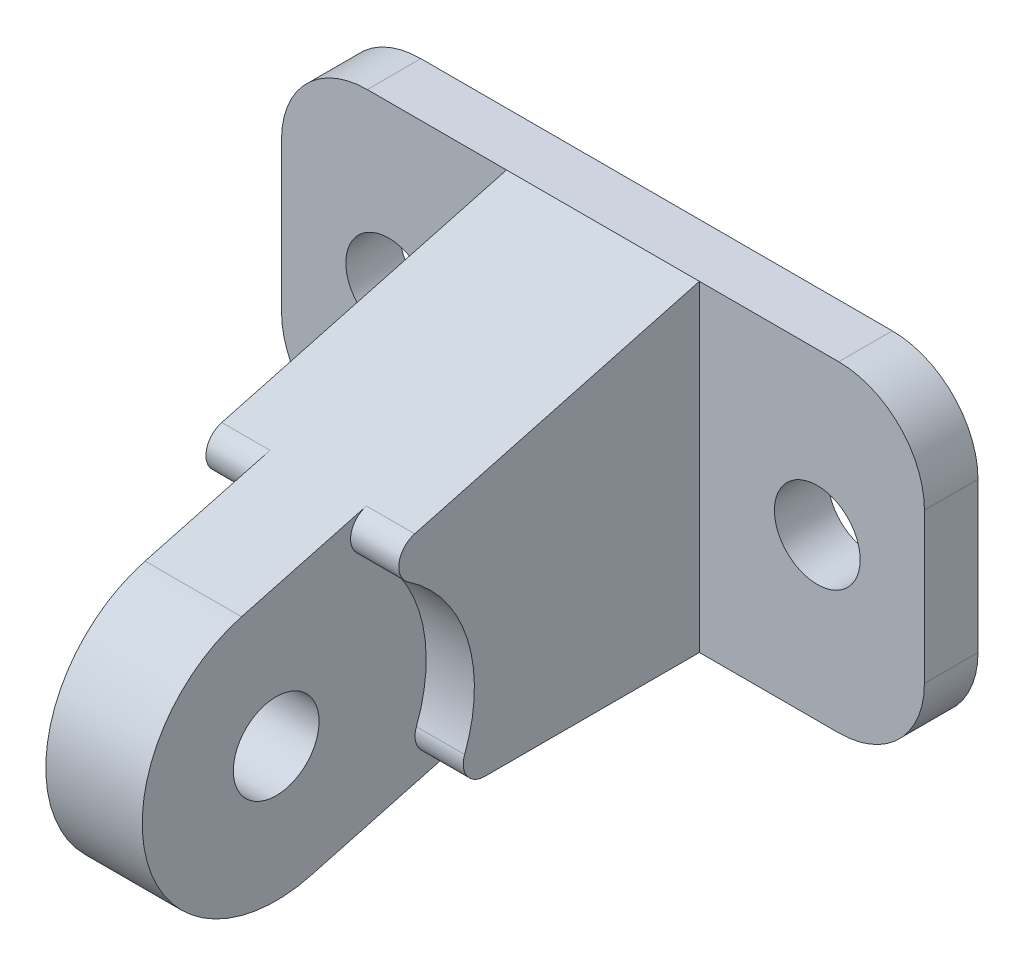
from build123d import *

# Parameters (mm, degrees)
SKETCH2_R                = 4
BOSS_EXTRUDE1_DEPTH      = 5
SKETCH3_R                = 4
BOSS_EXTRUDE2_DEPTH      = 4.5
BOSS_EXTRUDE2_DEPTH_BACK = 4.5
BOSS_EXTRUDE3_DEPTH      = 4.5
BOSS_EXTRUDE3_DEPTH_BACK = 13.5


with BuildPart() as part:
    # Sketch2 → Boss-Extrude1 (new body)
    with BuildSketch(Plane.XY):
        with BuildLine():
            Line((-22, 15), (22, 15))
            ThreePointArc((22, 15), (27.656854249, 12.656854249), (30, 7))
            Line((30, 7), (30, -7))
            ThreePointArc((30, -7), (27.656854249, -12.656854249), (22, -15))
            Line((22, -15), (-22, -15))
            ThreePointArc((-22, -15), (-27.656854249, -12.656854249), (-30, -7))
            Line((-30, -7), (-30, 7))
            ThreePointArc((-30, 7), (-27.656854249, 12.656854249), (-22, 15))
        make_face()
        with Locations((-20, 0)):
            Circle(SKETCH2_R, mode=Mode.SUBTRACT)
        with Locations((20, 0)):
            Circle(SKETCH2_R, mode=Mode.SUBTRACT)
    extrude(amount=BOSS_EXTRUDE1_DEPTH)

    # Sketch3 → Boss-Extrude2 (add, two sides)
    with BuildSketch(Plane(origin=(0, 0, 0), x_dir=(0, 0, -1), z_dir=(1, 0, 0))) as boss_extrude2_sk:
        with BuildLine():
            Line((-36.764761936, -19.393246819), (-5, -10.88190451))
            Line((-5, -10.88190451), (-5, 15))
            Line((-5, 15), (-43.235238064, 4.754898838))
            ThreePointArc((-43.235238064, 4.754898838), (-52.074072829, -10.554412054), (-36.764761936, -19.393246819))
        make_face()
        with Locations((-40, -7.31917399)):
            Circle(SKETCH3_R, mode=Mode.SUBTRACT)
    extrude(amount=BOSS_EXTRUDE2_DEPTH)
    extrude(boss_extrude2_sk.sketch, amount=-BOSS_EXTRUDE2_DEPTH_BACK)

    # Sketch4 → Boss-Extrude3 (add, two sides)
    with BuildSketch(Plane(origin=(4.5, 0, 0), x_dir=(0, 0, -1), z_dir=(1, 0, 0))) as boss_extrude3_sk:
        with BuildLine():
            Line((-25.04245288, -15), (-5, -15))
            Line((-5, -15), (-5, 15))
            Line((-5, 15), (-31.573908753, 7.87954261))
            ThreePointArc((-31.573908753, 7.87954261), (-33.028883618, 6.27753657), (-32.17423683, 4.289332839))
            ThreePointArc((-32.17423683, 4.289332839), (-26.655991742, -3.083912061), (-26.91214627, -12.289896749))
            ThreePointArc((-26.91214627, -12.289896749), (-26.688692003, -14.135736214), (-25.04245288, -15))
        make_face()
    extrude(amount=BOSS_EXTRUDE3_DEPTH)
    extrude(boss_extrude3_sk.sketch, amount=-BOSS_EXTRUDE3_DEPTH_BACK)


solid = part.part
